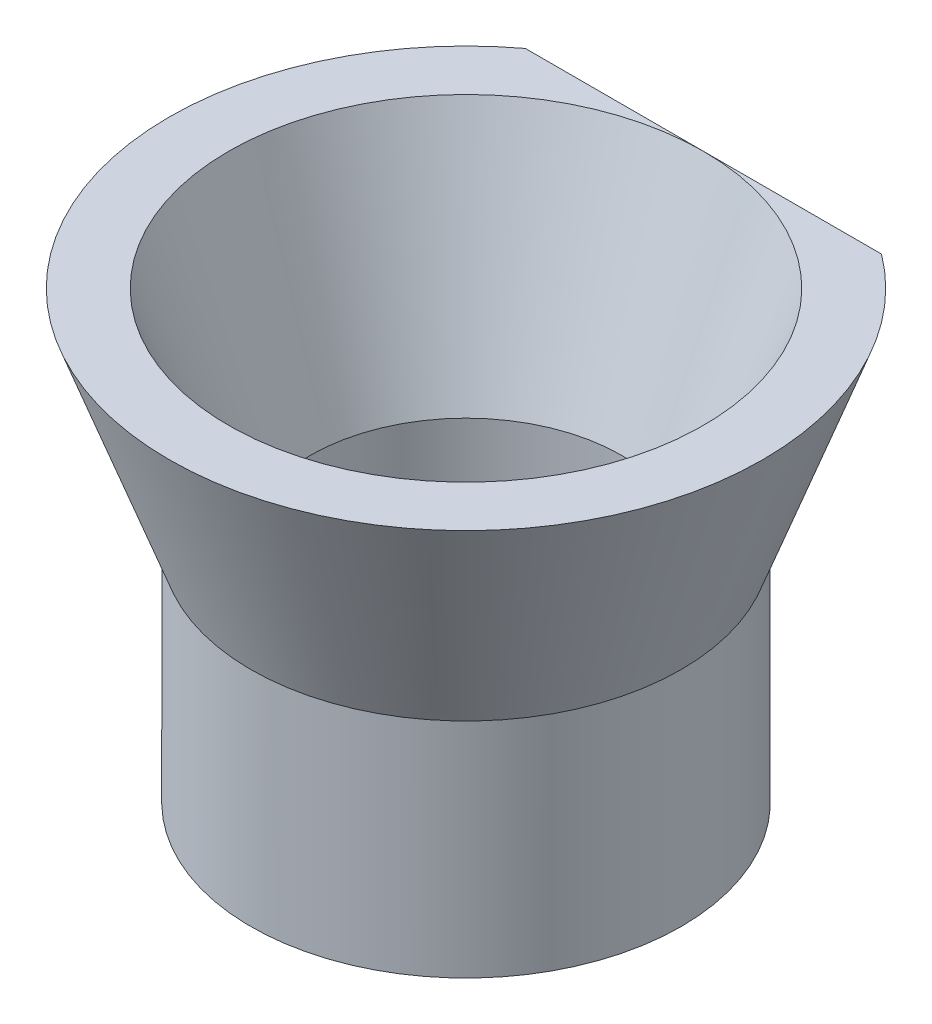
from build123d import *

# Parameters (mm, degrees)
CROQUIS2_R              = 7.25
CROQUIS2_R_2            = 5.25
SALIENTE_EXTRUIR1_DEPTH = 7.5
CORTAR_EXTRUIR1_DEPTH   = 7.5


with BuildPart() as part:
    # Croquis1 → Revolución1 (revolve)
    with BuildSketch(Plane.XY):
        Polygon((-5.25, 0), (-8, 7.5), (-10, 7.5), (-7.25, 0), align=None)
    revolve(axis=Axis((0, 7.5, 0), (0, -1, 0)))

    # Croquis2 → Saliente-Extruir1 (add)
    with BuildSketch(Plane.XZ):
        Circle(CROQUIS2_R)
        Circle(CROQUIS2_R_2, mode=Mode.SUBTRACT)
    extrude(amount=SALIENTE_EXTRUIR1_DEPTH)

    # Croquis4 → Cortar-Extruir1 (cut)
    with BuildSketch(Plane(origin=(0, 7.5, 0), x_dir=(1, 0, 0), z_dir=(0, 1, 0))):
        Polygon((-8.604100246, 8), (8.604100246, 8), (0, 12.592023512), align=None)
    extrude(amount=-CORTAR_EXTRUIR1_DEPTH, mode=Mode.SUBTRACT)


solid = part.part
